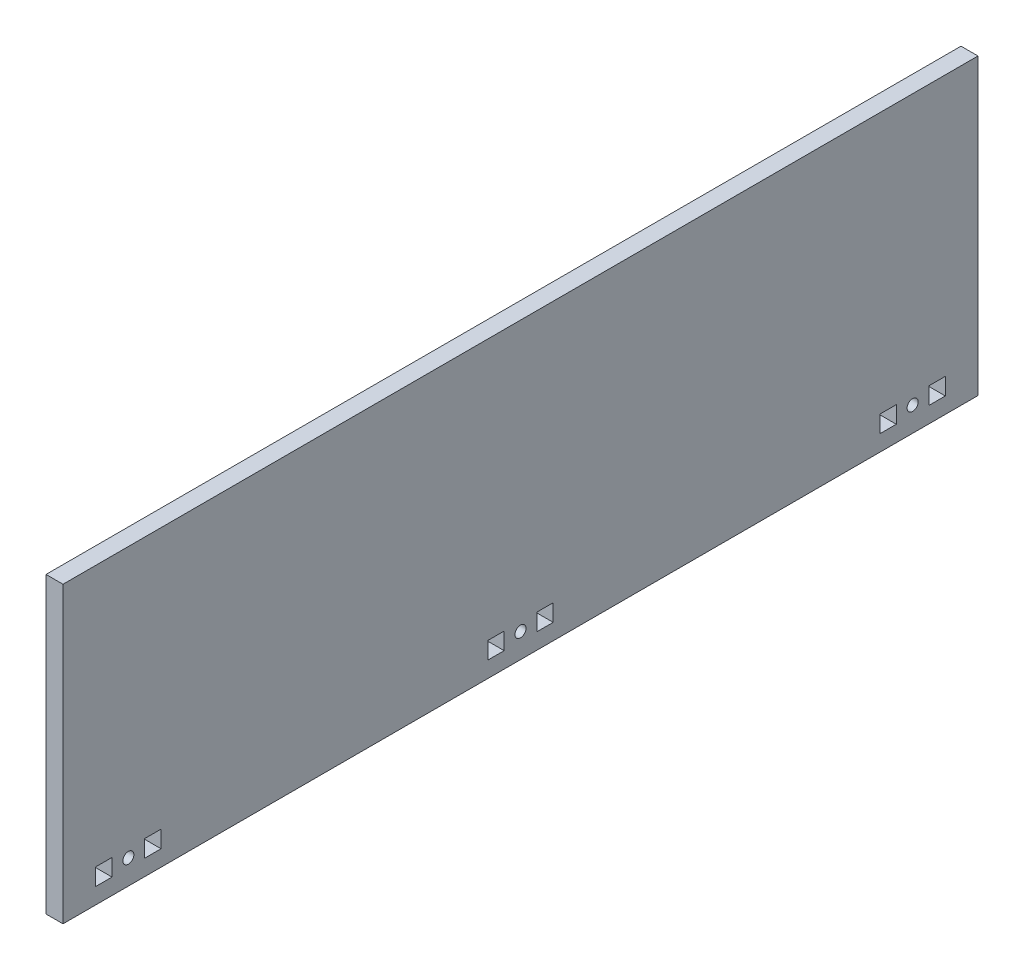
from build123d import *

# Parameters (mm, degrees)
SKETCH1_W           = 355.6
SKETCH1_H           = 114.3
SKETCH1_R           = 2.15265
SKETCH1_W_2         = 6.35
SKETCH1_H_2         = 6.604
BOSS_EXTRUDE1_DEPTH = 6.604


with BuildPart() as part:
    # Sketch1 → Boss-Extrude1 (new body)
    with BuildSketch(Plane(origin=(0, 0, 0), x_dir=(0, 0, -1), z_dir=(1, 0, 0))):
        with Locations((0, 57.15)):
            Rectangle(SKETCH1_W, SKETCH1_H)
        with Locations((-152.4, 9.525)):
            Circle(SKETCH1_R, mode=Mode.SUBTRACT)
        with Locations((0, 9.525)):
            Circle(SKETCH1_R, mode=Mode.SUBTRACT)
        with Locations((152.4, 9.525)):
            Circle(SKETCH1_R, mode=Mode.SUBTRACT)
        with Locations((-142.875, 9.525)):
            Rectangle(SKETCH1_W_2, SKETCH1_H_2, mode=Mode.SUBTRACT)
        with Locations((-161.925, 9.525)):
            Rectangle(SKETCH1_W_2, SKETCH1_H_2, mode=Mode.SUBTRACT)
        with Locations((9.525, 9.525)):
            Rectangle(SKETCH1_W_2, SKETCH1_H_2, mode=Mode.SUBTRACT)
        with Locations((-9.525, 9.525)):
            Rectangle(SKETCH1_W_2, SKETCH1_H_2, mode=Mode.SUBTRACT)
        with Locations((161.925, 9.525)):
            Rectangle(SKETCH1_W_2, SKETCH1_H_2, mode=Mode.SUBTRACT)
        with Locations((142.875, 9.525)):
            Rectangle(SKETCH1_W_2, SKETCH1_H_2, mode=Mode.SUBTRACT)
    extrude(amount=BOSS_EXTRUDE1_DEPTH)


solid = part.part
